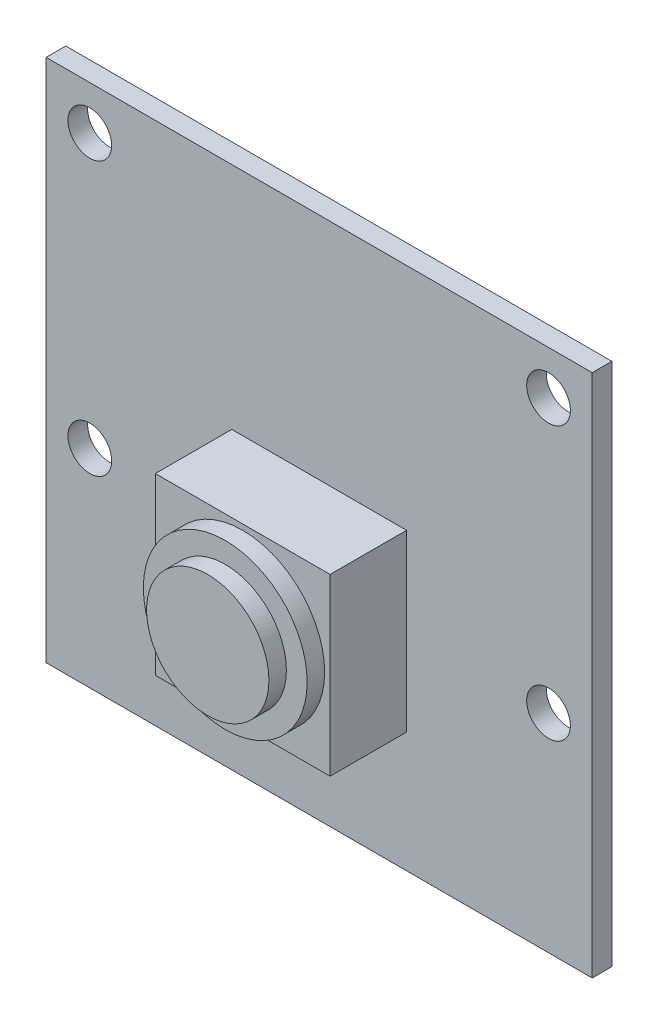
from build123d import *

# Parameters (mm, degrees)
CROQUIS1_W              = 25
CROQUIS1_H              = 24
CROQUIS1_R              = 1
SALIENTE_EXTRUIR1_DEPTH = 0.9
CROQUIS2_W              = 8
CROQUIS2_H              = 8
SALIENTE_EXTRUIR2_DEPTH = 3.5
CROQUIS3_R              = 3.75
SALIENTE_EXTRUIR3_DEPTH = 0.8
CROQUIS4_R              = 2.8
SALIENTE_EXTRUIR4_DEPTH = 0.8


with BuildPart() as part:
    # Croquis1 → Saliente-Extruir1 (new body)
    with BuildSketch(Plane.XY):
        Rectangle(CROQUIS1_W, CROQUIS1_H)
        with Locations((10.5, 10)):
            Circle(CROQUIS1_R, mode=Mode.SUBTRACT)
        with Locations((10.5, -2.5)):
            Circle(CROQUIS1_R, mode=Mode.SUBTRACT)
        with Locations((-10.5, -2.5)):
            Circle(CROQUIS1_R, mode=Mode.SUBTRACT)
        with Locations((-10.5, 10)):
            Circle(CROQUIS1_R, mode=Mode.SUBTRACT)
    extrude(amount=SALIENTE_EXTRUIR1_DEPTH)

    # Croquis2 → Saliente-Extruir2 (add)
    with BuildSketch(Plane.XY.offset(0.9)):
        with Locations((0, -2.5)):
            Rectangle(CROQUIS2_W, CROQUIS2_H)
    extrude(amount=SALIENTE_EXTRUIR2_DEPTH)

    # Croquis3 → Saliente-Extruir3 (add)
    with BuildSketch(Plane.XY.offset(4.4)):
        with Locations((0, -2.5)):
            Circle(CROQUIS3_R)
    extrude(amount=SALIENTE_EXTRUIR3_DEPTH)

    # Croquis4 → Saliente-Extruir4 (add)
    with BuildSketch(Plane.XY.offset(5.2)):
        with Locations((0, -2.5)):
            Circle(CROQUIS4_R)
    extrude(amount=SALIENTE_EXTRUIR4_DEPTH)


solid = part.part
